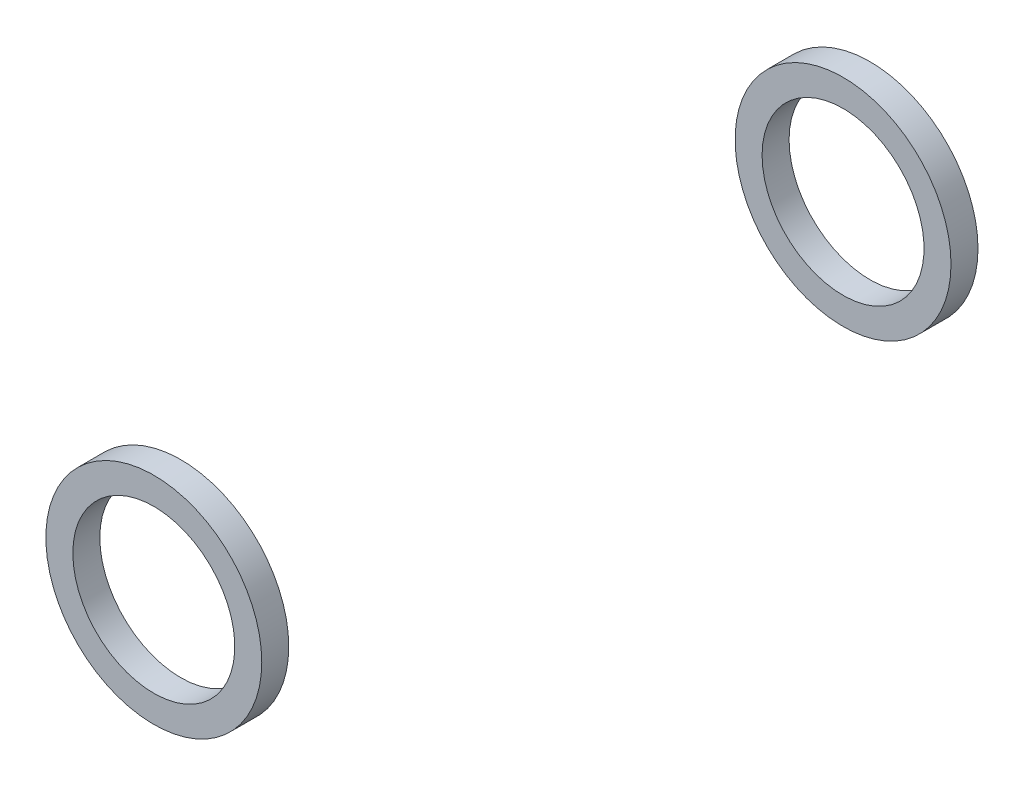
from build123d import *

# Parameters (mm, degrees)
SKETCH1_R               = 12.7
BOSS_EXTRUDE1_DEPTH     = 61.345
SKETCH2_R               = 20
SKETCH2_R_2             = 18
CUT_EXTRUDE2_DEPTH      = 1.85
SKETCH6_R               = 20
BOSS_EXTRUDE2_DEPTH     = 5
SKETCH7_R               = 15
CUT_EXTRUDE3_DEPTH      = 1
CUT_EXTRUDE3_DEPTH_BACK = 133.69


with BuildPart() as part:
    # Sketch1 → Boss-Extrude1 (new body)
    with BuildSketch(Plane.XY):
        Circle(SKETCH1_R)
    extrude(amount=BOSS_EXTRUDE1_DEPTH)

    # Sketch2 → Cut-Extrude2 (cut)
    with BuildSketch(Plane.XY.offset(61.345)):
        Circle(SKETCH2_R)
        Circle(SKETCH2_R_2, mode=Mode.SUBTRACT)
    extrude(amount=-CUT_EXTRUDE2_DEPTH, mode=Mode.SUBTRACT)

    # Sketch6 → Boss-Extrude2 (add)
    with BuildSketch(Plane.XY.offset(61.345)):
        Circle(SKETCH6_R)
    extrude(amount=BOSS_EXTRUDE2_DEPTH)

    # Mirror2: part across plane


with BuildPart() as part_1:
    add(part.part)
    add(part.part.mirror(Plane.XY))

    # Sketch7 → Cut-Extrude3 (cut, two sides)
    with BuildSketch(Plane(origin=(0, 0, -66.345), x_dir=(-1, 0, 0), z_dir=(0, 0, -1))) as cut_extrude3_sk:
        Circle(SKETCH7_R)
    extrude(amount=CUT_EXTRUDE3_DEPTH, mode=Mode.SUBTRACT)
    extrude(cut_extrude3_sk.sketch, amount=-CUT_EXTRUDE3_DEPTH_BACK, mode=Mode.SUBTRACT)


solid = part_1.part
